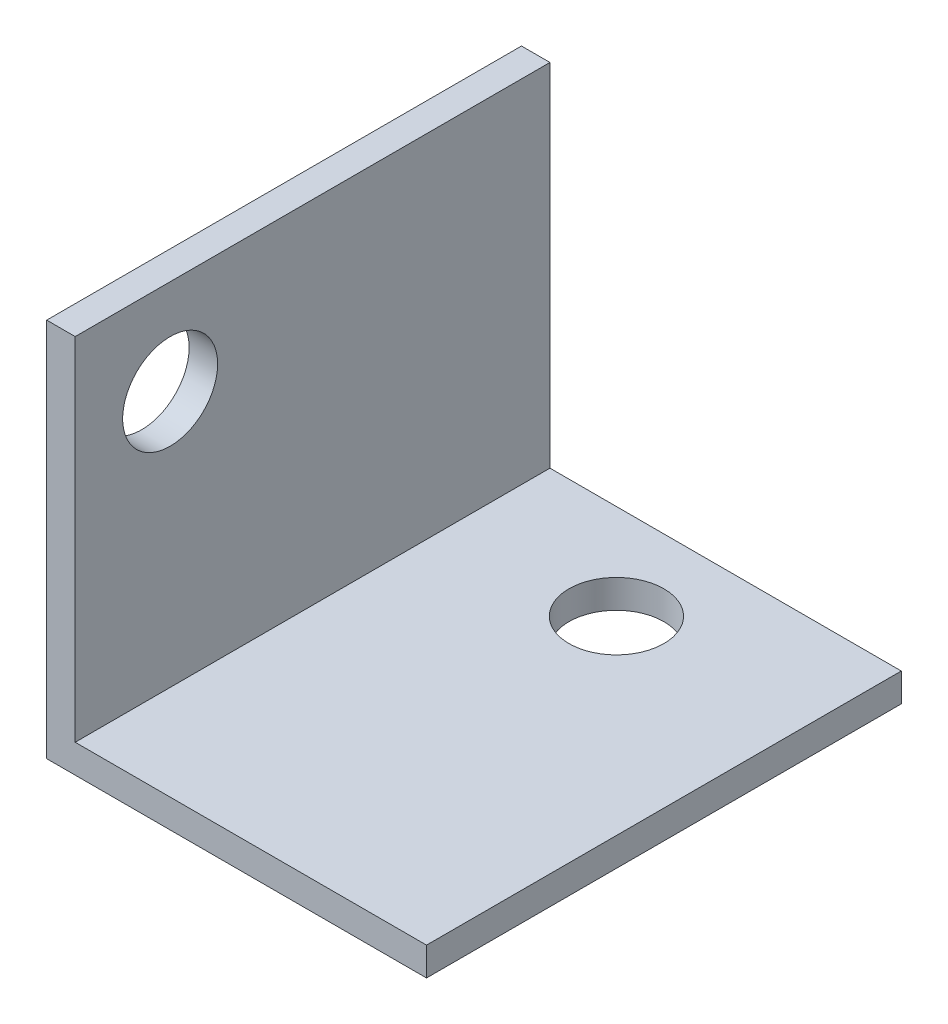
from build123d import *

# Parameters (mm, degrees)
EXTRUDE_THIN1_DEPTH = 25
SKETCH2_R           = 2.5
CUT_EXTRUDE1_DEPTH  = 38.749172176
SKETCH3_R           = 2.5
CUT_EXTRUDE2_DEPTH  = 37.976343789


with BuildPart() as part:
    # Sketch1 → Extrude-Thin1 (new body)
    with BuildSketch(Plane.XY):
        Polygon((0, 20), (0, 0), (20, 0), (20, 1.5), (1.5, 1.5), (1.5, 20), align=None)
    extrude(amount=EXTRUDE_THIN1_DEPTH)

    # Sketch2 → Cut-Extrude1 (cut, through all)
    with BuildSketch(Plane(origin=(0, 0, 0), x_dir=(-1, 0, 0), z_dir=(0, -1, 0))):
        with Locations((-10, -5)):
            Circle(SKETCH2_R)
    extrude(amount=-CUT_EXTRUDE1_DEPTH, mode=Mode.SUBTRACT)

    # Sketch3 → Cut-Extrude2 (cut, through all)
    with BuildSketch(Plane(origin=(1.5, 0, 0), x_dir=(0, 0, -1), z_dir=(1, 0, 0))):
        with Locations((-20, 15)):
            Circle(SKETCH3_R)
    extrude(amount=-CUT_EXTRUDE2_DEPTH, mode=Mode.SUBTRACT)


solid = part.part
